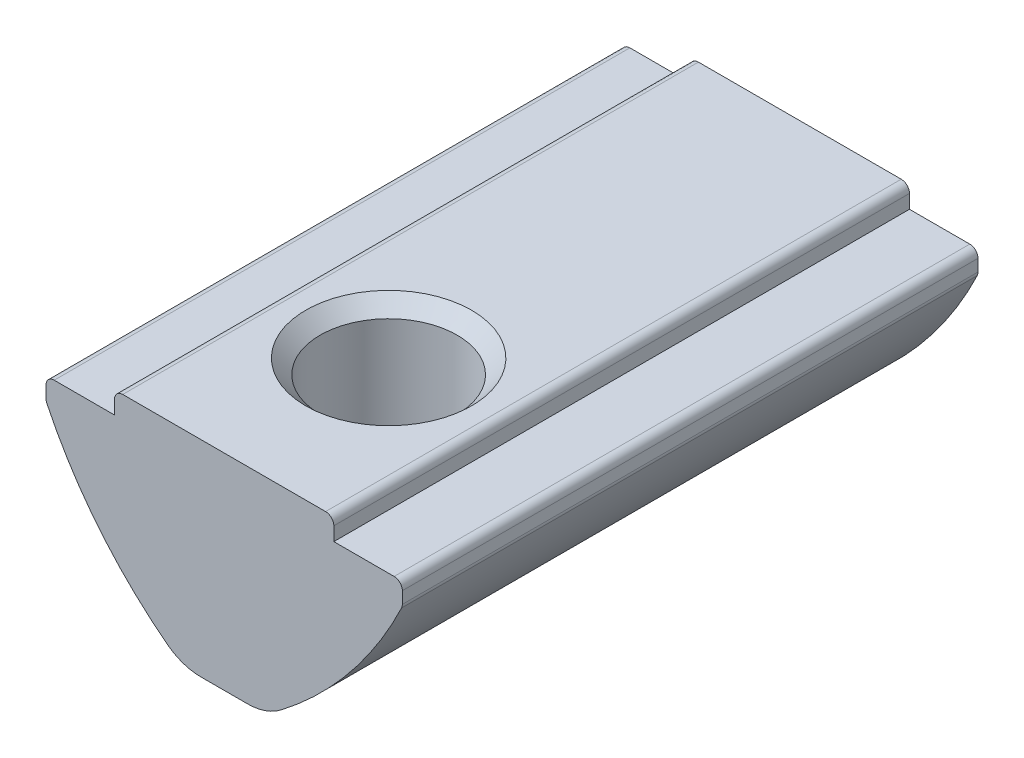
from build123d import *

# Parameters (mm, degrees)
EXTRUDE_1_DEPTH             = 10.5
FILLET_1_R                  = 0.3
FILLET_2_R                  = 2
HOLE_WIZARD_M62_D           = 5
HOLE_WIZARD_M62_CSINK_D     = 6.05
HOLE_WIZARD_M62_CSINK_ANGLE = 90


with BuildPart() as part:
    # Эскиз1 → Бобышка-Вытянуть1 (new body, symmetric)
    with BuildSketch(Plane.XY):
        with BuildLine():
            Line((-4, 0), (4, 0))
            Line((4, 0), (4, -0.8))
            Line((4, -0.8), (6.5, -0.8))
            Line((6.5, -0.8), (6.5, -1.6))
            ThreePointArc((6.5, -1.6), (4.386776199, -4.87777644), (1.5, -7.5))
            Line((1.5, -7.5), (-1.5, -7.5))
            ThreePointArc((-1.5, -7.5), (-4.386776199, -4.87777644), (-6.5, -1.6))
            Line((-6.5, -1.6), (-6.5, -0.8))
            Line((-6.5, -0.8), (-4, -0.8))
            Line((-4, -0.8), (-4, 0))
        make_face()
    extrude(amount=EXTRUDE_1_DEPTH, both=True)

    # Скругление1
    fillet_1_edges = [part.edges().sort_by_distance(p)[0] for p in [
        (6.5, -0.8, 0),
        (6.5, -1.6, 0),
        (-6.5, -1.6, 0),
        (-6.5, -0.8, 0),
        (-4, 0, 0),
        (4, 0, 0),
    ]]
    fillet(fillet_1_edges, radius=FILLET_1_R)

    # Скругление2
    fillet_2_edges = [part.edges().sort_by_distance(p)[0] for p in [
        (1.5, -7.5, 0),
        (-1.5, -7.5, 0),
    ]]
    fillet(fillet_2_edges, radius=FILLET_2_R)

    # Отверстие обработанное метчиком M62 (through all)
    with Locations(Plane(origin=(0, 0, 0), x_dir=(1, 0, 0), z_dir=(0, 1, 0))):
        with Locations((0, -4.5)):
            CounterSinkHole(HOLE_WIZARD_M62_D / 2, HOLE_WIZARD_M62_CSINK_D / 2, counter_sink_angle=HOLE_WIZARD_M62_CSINK_ANGLE)

    # Эскиз5 → Повернуть1 (revolve)
    with BuildSketch(Plane(origin=(0, 0, 0), x_dir=(0, 0, -1), z_dir=(1, 0, 0))):
        with BuildLine():
            Line((6.5, -4.3), (6.5, -8.3))
            ThreePointArc((6.5, -8.3), (4.5, -6.3), (6.5, -4.3))
        make_face()
    revolve(axis=Axis((0, -4.3, -6.5), (0, -1, 0)))


solid = part.part
